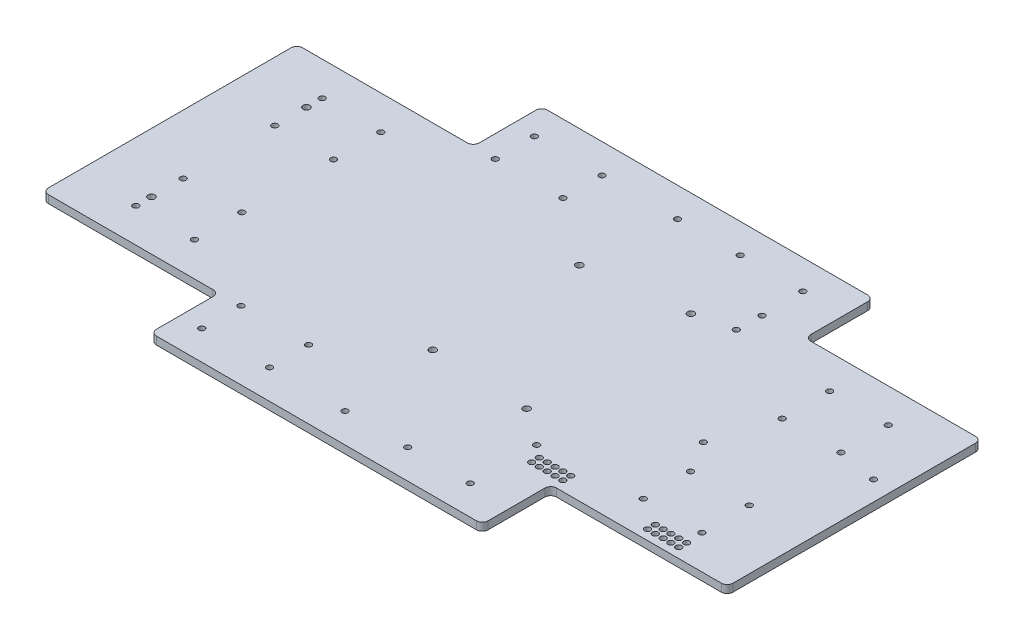
from build123d import *

# Parameters (mm, degrees)
SKETCH_1_R          = 1.75
SKETCH_1_R_2        = 1.5
EXTRUDE_1_DEPTH     = 4
SKETCH_2_R          = 1.5
CUT_EXTRUDE_1_DEPTH = 248.310677228
FILLET_1_R          = 3
FILLET_2_R          = 3
FILLET_3_R          = 3
FILLET_4_R          = 3
FILLET_5_R          = 3
FILLET_6_R          = 3
FILLET_7_R          = 3
FILLET_8_R          = 3
FILLET_9_R          = 3
FILLET_10_R         = 3
FILLET_11_R         = 3
FILLET_12_R         = 3
SKETCH_3_R          = 1.75
CUT_EXTRUDE_2_DEPTH = 248.310677228
SKETCH_5_R          = 1.5
CUT_EXTRUDE_3_DEPTH = 248.310677228
SKETCH_6_R          = 1.5
CUT_EXTRUDE_4_DEPTH = 10


with BuildPart() as part:
    # 草图1 → 凸台-拉伸1 (new body)
    with BuildSketch(Plane(origin=(0, 0, 0), x_dir=(1, 0, 0), z_dir=(0, 1, 0))):
        Polygon((-165.354330709, -0.523412356), (-165.354330709, 129.476587644), (-75.154330709, 129.476587644), (-75.154330709, 164.476587644), (94.445669291, 164.476587644), (94.445669291, 129.476587644), (184.645669291, 129.476587644), (184.645669291, -0.523412356), (94.445669291, -0.523412356), (94.445669291, -35.523412356), (-75.154330709, -35.523412356), (-75.154330709, -0.523412356), align=None)
        with Locations((-135.060351007, 24.855830169)):
            Circle(SKETCH_1_R, mode=Mode.SUBTRACT)
        with Locations((-135.060351007, 104.097345119)):
            Circle(SKETCH_1_R, mode=Mode.SUBTRACT)
        with Locations((-105.060351007, 87.897345119)):
            Circle(SKETCH_1_R_2, mode=Mode.SUBTRACT)
        with Locations((-105.060351007, 112.097345119)):
            Circle(SKETCH_1_R_2, mode=Mode.SUBTRACT)
        with Locations((-135.060351007, 87.897345119)):
            Circle(SKETCH_1_R_2, mode=Mode.SUBTRACT)
        with Locations((-135.060351007, 112.097345119)):
            Circle(SKETCH_1_R_2, mode=Mode.SUBTRACT)
        with Locations((-105.060351007, 41.055830169)):
            Circle(SKETCH_1_R_2, mode=Mode.SUBTRACT)
        with Locations((-135.060351007, 41.055830169)):
            Circle(SKETCH_1_R_2, mode=Mode.SUBTRACT)
        with Locations((-105.060351007, 16.855830169)):
            Circle(SKETCH_1_R_2, mode=Mode.SUBTRACT)
        with Locations((-135.060351007, 16.855830169)):
            Circle(SKETCH_1_R_2, mode=Mode.SUBTRACT)
        with Locations((124.351689589, 16.855830169)):
            Circle(SKETCH_1_R_2, mode=Mode.SUBTRACT)
        with Locations((154.351689589, 16.855830169)):
            Circle(SKETCH_1_R_2, mode=Mode.SUBTRACT)
        with Locations((124.351689589, 41.055830169)):
            Circle(SKETCH_1_R_2, mode=Mode.SUBTRACT)
        with Locations((154.351689589, 41.055830169)):
            Circle(SKETCH_1_R_2, mode=Mode.SUBTRACT)
        with Locations((124.351689589, 87.897345119)):
            Circle(SKETCH_1_R_2, mode=Mode.SUBTRACT)
        with Locations((154.351689589, 87.897345119)):
            Circle(SKETCH_1_R_2, mode=Mode.SUBTRACT)
        with Locations((124.351689589, 112.097345119)):
            Circle(SKETCH_1_R_2, mode=Mode.SUBTRACT)
        with Locations((154.351689589, 112.097345119)):
            Circle(SKETCH_1_R_2, mode=Mode.SUBTRACT)
    extrude(amount=EXTRUDE_1_DEPTH)

    # 草图2 → 切除-拉伸1 (cut, through all)
    with BuildSketch(Plane(origin=(0, 4, 0), x_dir=(1, 0, 0), z_dir=(0, 1, 0))):
        with Locations((-29.350172185, 149.476587644)):
            Circle(SKETCH_2_R)
        with Locations((-29.350172185, 129.476587644)):
            Circle(SKETCH_2_R)
        with Locations((-63.922255051, 149.476587644)):
            Circle(SKETCH_2_R)
        with Locations((-63.922255051, 129.476587644)):
            Circle(SKETCH_2_R)
        with Locations((-29.350172185, -0.523412356)):
            Circle(SKETCH_2_R)
        with Locations((-29.350172185, -20.523412356)):
            Circle(SKETCH_2_R)
        with Locations((-63.922255051, -20.523412356)):
            Circle(SKETCH_2_R)
        with Locations((-63.922255051, -0.523412356)):
            Circle(SKETCH_2_R)
        with Locations((9.288549374, 149.476587644)):
            Circle(SKETCH_2_R)
        with Locations((41.288549374, 149.476587644)):
            Circle(SKETCH_2_R)
        with Locations((73.288549374, 149.476587644)):
            Circle(SKETCH_2_R)
        with Locations((73.288549374, 115.508346765)):
            Circle(SKETCH_2_R)
        with Locations((41.288549374, -20.523412356)):
            Circle(SKETCH_2_R)
        with Locations((73.288549374, -20.523412356)):
            Circle(SKETCH_2_R)
        with Locations((73.288549374, 13.444828523)):
            Circle(SKETCH_2_R)
        with Locations((9.288549374, -20.523412356)):
            Circle(SKETCH_2_R)
    extrude(amount=-CUT_EXTRUDE_1_DEPTH, mode=Mode.SUBTRACT)

    # 圆角1
    fillet_1_edges = [part.edges().sort_by_distance(p)[0] for p in [
        (-75.154330709, 2, -164.476587644),
    ]]
    fillet(fillet_1_edges, radius=FILLET_1_R)

    # 圆角2
    fillet_2_edges = [part.edges().sort_by_distance(p)[0] for p in [
        (-165.354330709, 2, -129.476587644),
    ]]
    fillet(fillet_2_edges, radius=FILLET_2_R)

    # 圆角3
    fillet_3_edges = [part.edges().sort_by_distance(p)[0] for p in [
        (-75.154330709, 2, -129.476587644),
    ]]
    fillet(fillet_3_edges, radius=FILLET_3_R)

    # 圆角4
    fillet_4_edges = [part.edges().sort_by_distance(p)[0] for p in [
        (-165.354330709, 2, 0.523412356),
    ]]
    fillet(fillet_4_edges, radius=FILLET_4_R)

    # 圆角5
    fillet_5_edges = [part.edges().sort_by_distance(p)[0] for p in [
        (-75.154330709, 2, 0.523412356),
    ]]
    fillet(fillet_5_edges, radius=FILLET_5_R)

    # 圆角6
    fillet_6_edges = [part.edges().sort_by_distance(p)[0] for p in [
        (-75.154330709, 2, 35.523412356),
    ]]
    fillet(fillet_6_edges, radius=FILLET_6_R)

    # 圆角7
    fillet_7_edges = [part.edges().sort_by_distance(p)[0] for p in [
        (94.445669291, 2, 35.523412356),
    ]]
    fillet(fillet_7_edges, radius=FILLET_7_R)

    # 圆角8
    fillet_8_edges = [part.edges().sort_by_distance(p)[0] for p in [
        (94.445669291, 2, 0.523412356),
    ]]
    fillet(fillet_8_edges, radius=FILLET_8_R)

    # 圆角9
    fillet_9_edges = [part.edges().sort_by_distance(p)[0] for p in [
        (184.645669291, 2, 0.523412356),
    ]]
    fillet(fillet_9_edges, radius=FILLET_9_R)

    # 圆角10
    fillet_10_edges = [part.edges().sort_by_distance(p)[0] for p in [
        (184.645669291, 2, -129.476587644),
    ]]
    fillet(fillet_10_edges, radius=FILLET_10_R)

    # 圆角11
    fillet_11_edges = [part.edges().sort_by_distance(p)[0] for p in [
        (94.445669291, 2, -129.476587644),
    ]]
    fillet(fillet_11_edges, radius=FILLET_11_R)

    # 圆角12
    fillet_12_edges = [part.edges().sort_by_distance(p)[0] for p in [
        (94.445669291, 2, -164.476587644),
    ]]
    fillet(fillet_12_edges, radius=FILLET_12_R)

    # 草图3 → 切除-拉伸2 (cut, through all)
    with BuildSketch(Plane(origin=(0, 4, 0), x_dir=(1, 0, 0), z_dir=(0, 1, 0))):
        with Locations((54.598317565, 26.976587644)):
            Circle(SKETCH_3_R)
        with Locations((54.598317565, 110.976587644)):
            Circle(SKETCH_3_R)
        with Locations((4.598317565, 28.976587644)):
            Circle(SKETCH_3_R)
        with Locations((4.598317565, 103.976587644)):
            Circle(SKETCH_3_R)
    extrude(amount=-CUT_EXTRUDE_2_DEPTH, mode=Mode.SUBTRACT)

    # 草图5 → 切除-拉伸3 (cut, through all)
    with BuildSketch(Plane(origin=(0, 4, 0), x_dir=(1, 0, 0), z_dir=(0, 1, 0))):
        with Locations((73.645669291, 128.296587644)):
            Circle(SKETCH_5_R)
        with Locations((174.645669291, 84.296587644)):
            Circle(SKETCH_5_R)
        with Locations((114.645669291, 57.296587644)):
            Circle(SKETCH_5_R)
    extrude(amount=-CUT_EXTRUDE_3_DEPTH, mode=Mode.SUBTRACT)

    # 草图6 → 切除-拉伸4 (cut)
    with BuildSketch(Plane(origin=(0, 4, 0), x_dir=(1, 0, 0), z_dir=(0, 1, 0))):
        with Locations((87.635669291, 8.486587644)):
            Circle(SKETCH_6_R)
        with Locations((146.895669291, 8.486587644)):
            Circle(SKETCH_6_R)
        with Locations((83.635669291, 8.486587644)):
            Circle(SKETCH_6_R)
        with Locations((142.895669291, 8.486587644)):
            Circle(SKETCH_6_R)
        with Locations((79.635669291, 8.486587644)):
            Circle(SKETCH_6_R)
        with Locations((138.895669291, 8.486587644)):
            Circle(SKETCH_6_R)
        with Locations((91.635669291, 8.486587644)):
            Circle(SKETCH_6_R)
        with Locations((150.895669291, 8.486587644)):
            Circle(SKETCH_6_R)
        with Locations((95.635669291, 8.486587644)):
            Circle(SKETCH_6_R)
        with Locations((154.895669291, 8.486587644)):
            Circle(SKETCH_6_R)
        with Locations((87.635669291, 4.486587644)):
            Circle(SKETCH_6_R)
        with Locations((146.895669291, 4.486587644)):
            Circle(SKETCH_6_R)
        with Locations((79.635669291, 4.486587644)):
            Circle(SKETCH_6_R)
        with Locations((83.635669291, 4.486587644)):
            Circle(SKETCH_6_R)
        with Locations((91.635669291, 4.486587644)):
            Circle(SKETCH_6_R)
        with Locations((95.635669291, 4.486587644)):
            Circle(SKETCH_6_R)
        with Locations((138.895669291, 4.486587644)):
            Circle(SKETCH_6_R)
        with Locations((142.895669291, 4.486587644)):
            Circle(SKETCH_6_R)
        with Locations((150.895669291, 4.486587644)):
            Circle(SKETCH_6_R)
        with Locations((154.895669291, 4.486587644)):
            Circle(SKETCH_6_R)
    extrude(amount=-CUT_EXTRUDE_4_DEPTH, mode=Mode.SUBTRACT)


solid = part.part
